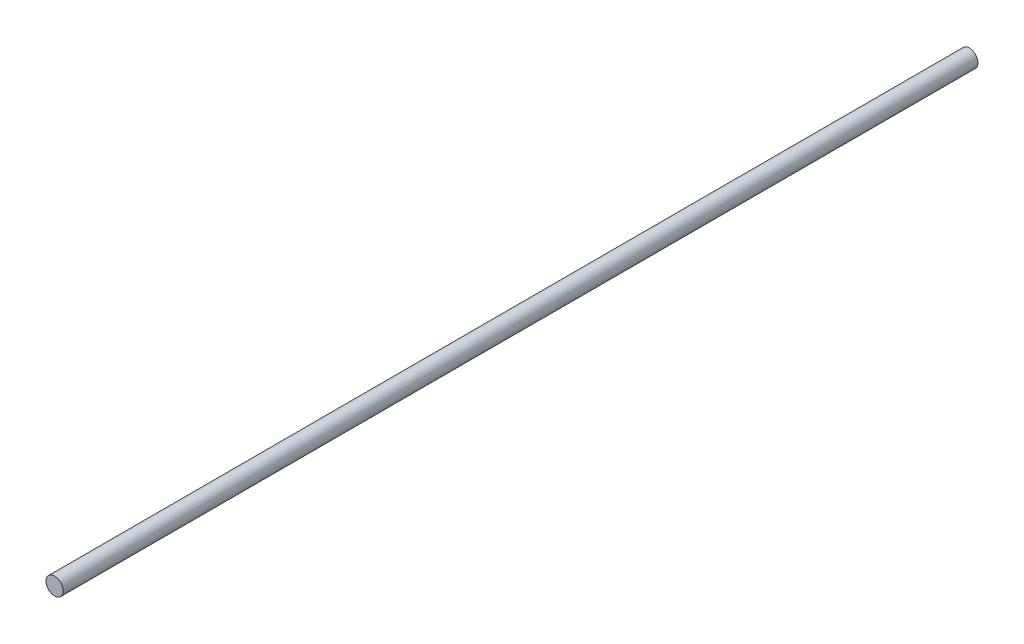
from build123d import *

# Parameters (mm, degrees)
SKETCH1_R           = 4
BOSS_EXTRUDE1_DEPTH = 425


with BuildPart() as part:
    # Sketch1 → Boss-Extrude1 (new body)
    with BuildSketch(Plane.XY):
        Circle(SKETCH1_R)
    extrude(amount=BOSS_EXTRUDE1_DEPTH)


solid = part.part
